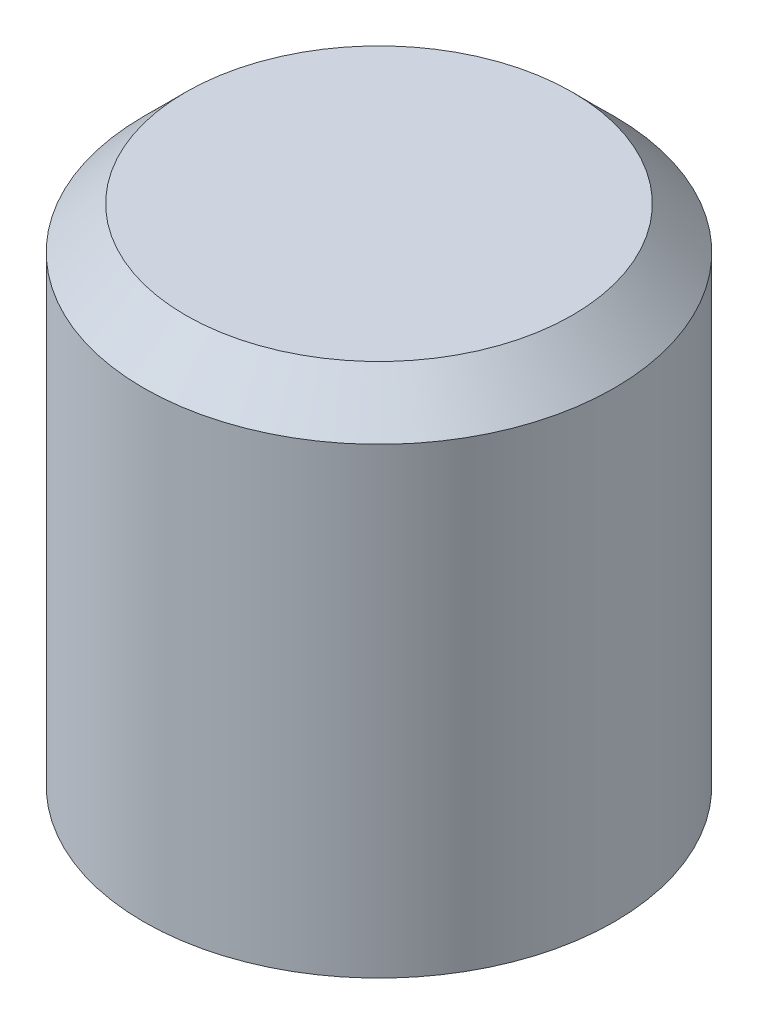
from build123d import *

# Parameters (mm, degrees)
SKETCH1_R           = 1.4
BOSS_EXTRUDE1_DEPTH = 3
CHAMFER1_SIZE       = 0.25


with BuildPart() as part:
    # Sketch1 → Boss-Extrude1 (new body)
    with BuildSketch(Plane(origin=(0, 0, 0), x_dir=(1, 0, 0), z_dir=(0, 1, 0))):
        Circle(SKETCH1_R)
    extrude(amount=BOSS_EXTRUDE1_DEPTH)

    # Chamfer1
    chamfer1_edges = [part.edges().sort_by_distance(p)[0] for p in [
        (-1.4, 3, 0),
    ]]
    chamfer(chamfer1_edges, length=CHAMFER1_SIZE)


solid = part.part
